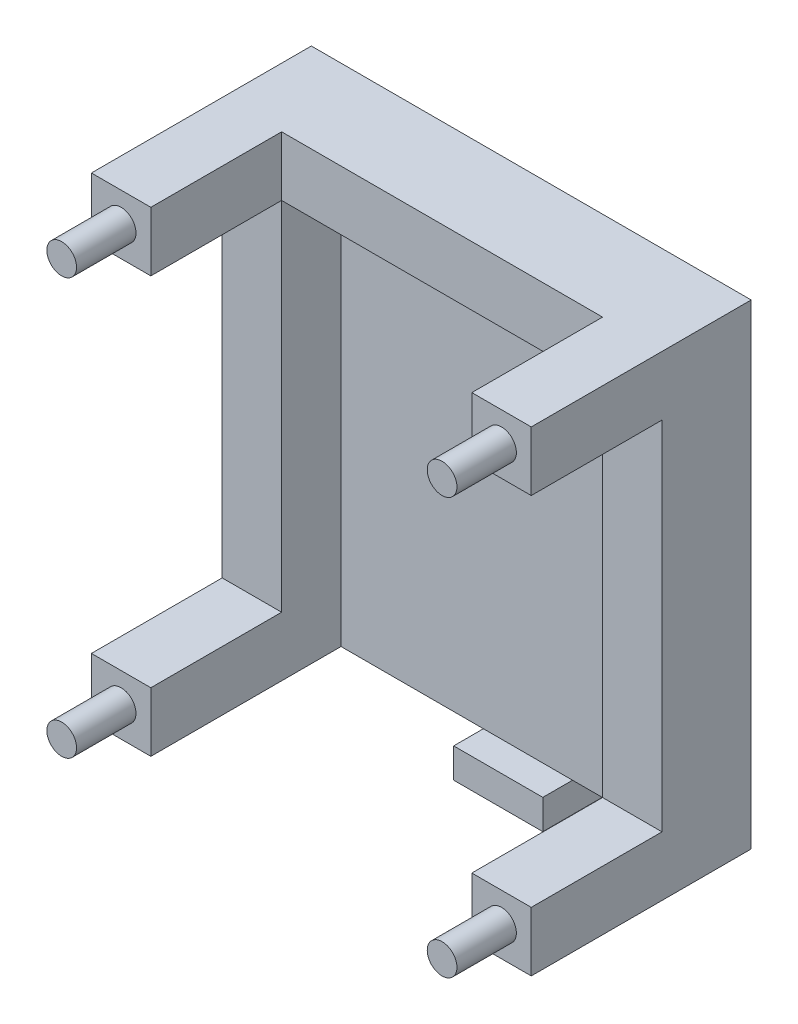
from build123d import *

# Parameters (mm, degrees)
CROQUIS1_W               = 54
CROQUIS1_H               = 70
SALIENTE_EXTRUIR1_DEPTH  = 5
CROQUIS4_W               = 54
CROQUIS4_H               = 10
SALIENTE_EXTRUIR5_DEPTH  = 15
CROQUIS5_W               = 10
CROQUIS5_H               = 10
SALIENTE_EXTRUIR6_DEPTH  = 37
CROQUIS6_W               = 15
CROQUIS6_H               = 5
SALIENTE_EXTRUIR7_DEPTH  = 10
CROQUIS8_W               = 10
CROQUIS8_H               = 60
SALIENTE_EXTRUIR9_DEPTH  = 15
CROQUIS9_R               = 2.5
SALIENTE_EXTRUIR10_DEPTH = 10
CROQUIS11_R              = 2.55
CORTAR_EXTRUIR1_DEPTH    = 10


with BuildPart() as part:
    # Croquis1 → Saliente-Extruir1 (new body)
    with BuildSketch(Plane.XY):
        with Locations((28.400543811, 1.50863747)):
            Rectangle(CROQUIS1_W, CROQUIS1_H)
    extrude(amount=SALIENTE_EXTRUIR1_DEPTH)

    # Croquis4 → Saliente-Extruir5 (add)
    with BuildSketch(Plane(origin=(0, 0, 0), x_dir=(-1, 0, 0), z_dir=(0, 0, -1))):
        with Locations((-28.400543811, 41.50863747)):
            Rectangle(CROQUIS4_W, CROQUIS4_H)
    extrude(amount=-SALIENTE_EXTRUIR5_DEPTH)

    # Croquis5 → Saliente-Extruir6 (add)
    with BuildSketch(Plane(origin=(0, 0, 0), x_dir=(-1, 0, 0), z_dir=(0, 0, -1))):
        with Locations((-60.400543811, 41.50863747)):
            Rectangle(CROQUIS5_W, CROQUIS5_H)
        with Locations((-60.400543811, -28.49136253)):
            Rectangle(CROQUIS5_W, CROQUIS5_H)
        with Locations((3.599456189, -28.49136253)):
            Rectangle(CROQUIS5_W, CROQUIS5_H)
        with Locations((3.599456189, 41.50863747)):
            Rectangle(CROQUIS5_W, CROQUIS5_H)
    extrude(amount=-SALIENTE_EXTRUIR6_DEPTH)

    # Croquis8 → Saliente-Extruir9 (add)
    with BuildSketch(Plane(origin=(0, 0, 0), x_dir=(-1, 0, 0), z_dir=(0, 0, -1))):
        with Locations((-60.400543811, 6.50863747)):
            Rectangle(CROQUIS8_W, CROQUIS8_H)
        with Locations((3.599456189, 6.50863747)):
            Rectangle(CROQUIS8_W, CROQUIS8_H)
    extrude(amount=-SALIENTE_EXTRUIR9_DEPTH)

    # Croquis9 → Saliente-Extruir10 (add)
    with BuildSketch(Plane.XY.offset(37)):
        with BuildLine():
            ThreePointArc((-1.099456189, 41.50863747), (-3.599456189, 44.00863747), (-6.099456189, 41.50863747))
            Line((-6.099456189, 41.50863747), (-1.099456189, 41.50863747))
        make_face()
        with BuildLine():
            Line((-1.099456189, 41.50863747), (-6.099456189, 41.50863747))
            ThreePointArc((-6.099456189, 41.50863747), (-3.599456189, 39.00863747), (-1.099456189, 41.50863747))
        make_face()
        with Locations((60.400543811, 41.50863747)):
            Circle(CROQUIS9_R)
        with Locations((60.400543811, -28.49136253)):
            Circle(CROQUIS9_R)
        with Locations((-3.599456189, -28.49136253)):
            Circle(CROQUIS9_R)
    extrude(amount=SALIENTE_EXTRUIR10_DEPTH)

    # Croquis11 → Cortar-Extruir1 (cut)
    with BuildSketch(Plane(origin=(0, 0, 0), x_dir=(-1, 0, 0), z_dir=(0, 0, -1))):
        with BuildLine():
            ThreePointArc((-57.850543811, 41.50863747), (-60.400543811, 44.05863747), (-62.950543811, 41.50863747))
            Line((-62.950543811, 41.50863747), (-60.400543811, 41.50863747))
            Line((-60.400543811, 41.50863747), (-57.850543811, 41.50863747))
        make_face()
        with BuildLine():
            Line((-60.400543811, 41.50863747), (-62.950543811, 41.50863747))
            ThreePointArc((-62.950543811, 41.50863747), (-60.400543811, 38.95863747), (-57.850543811, 41.50863747))
            Line((-57.850543811, 41.50863747), (-60.400543811, 41.50863747))
        make_face()
        with BuildLine():
            ThreePointArc((6.149456189, 41.50863747), (3.599456189, 44.05863747), (1.049456189, 41.50863747))
            Line((1.049456189, 41.50863747), (6.149456189, 41.50863747))
        make_face()
        with BuildLine():
            Line((6.149456189, 41.50863747), (1.049456189, 41.50863747))
            ThreePointArc((1.049456189, 41.50863747), (3.599456189, 38.95863747), (6.149456189, 41.50863747))
        make_face()
        with Locations((3.599456189, -28.49136253)):
            Circle(CROQUIS11_R)
        with Locations((-60.400543811, -28.49136253)):
            Circle(CROQUIS11_R)
    extrude(amount=-CORTAR_EXTRUIR1_DEPTH, mode=Mode.SUBTRACT)


with BuildPart() as body_2:
    # Croquis6 → Saliente-Extruir7 (new body)
    with BuildSketch(Plane(origin=(0, 0, 0), x_dir=(-1, 0, 0), z_dir=(0, 0, -1))):
        with Locations((-32.848967284, -35.99136253)):
            Rectangle(CROQUIS6_W, CROQUIS6_H)
    extrude(amount=-SALIENTE_EXTRUIR7_DEPTH)


solid = Compound([part.part, body_2.part])
